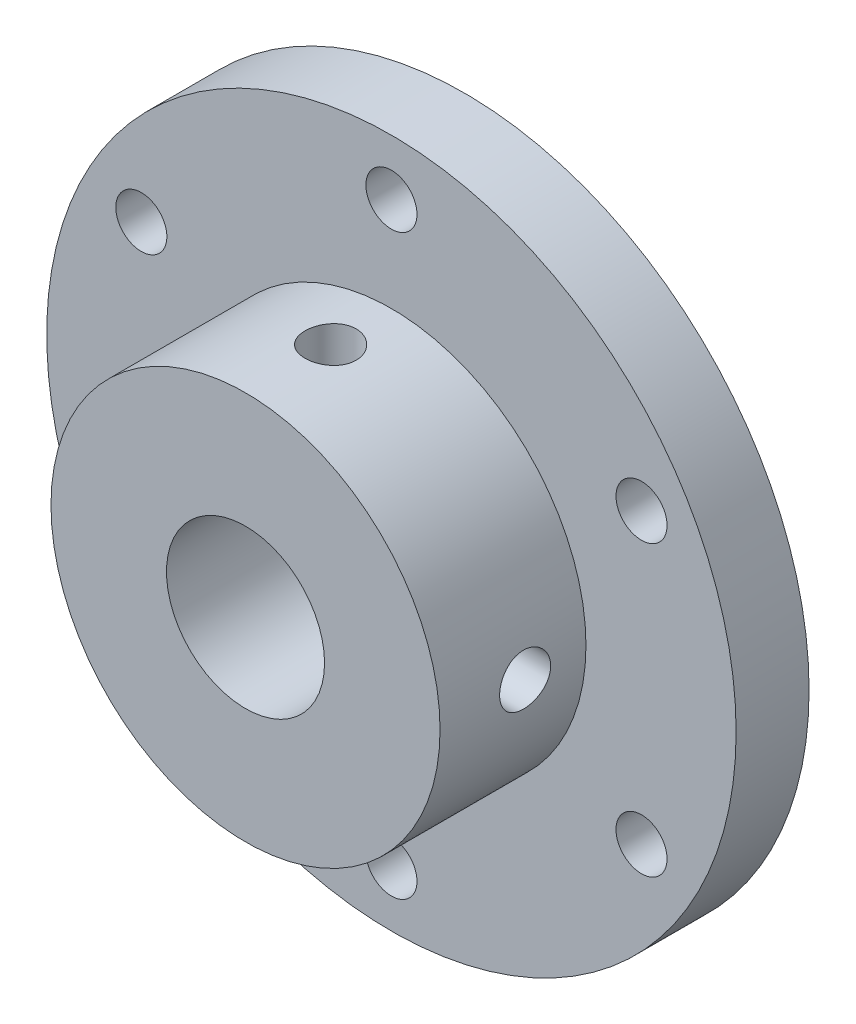
from build123d import *

# Parameters (mm, degrees)
SKETCH_1_R               = 28.35
EXTRUDE_1_DEPTH          = 6
SKETCH_2_R               = 16
EXTRUDE_2_DEPTH          = 12
SKETCH_3_R               = 6.5
CUT_EXTRUDE_1_DEPTH      = 44.948208155
HOLE_WIZARD_M5_2_D       = 4.2
PATTERN_CIRCULAR_1_COUNT = 6
CUT_EXTRUDE_3_REACH      = 57.63
SKETCH_6_R               = 2.1
PATTERN_CIRCULAR_2_COUNT = 2
PATTERN_CIRCULAR_2_ANGLE = 90


with BuildPart() as part:
    # 草圖1 → 填料-伸長1 (new body)
    with BuildSketch(Plane.XY):
        Circle(SKETCH_1_R)
    extrude(amount=EXTRUDE_1_DEPTH)

    # 草圖2 → 填料-伸長2 (add)
    with BuildSketch(Plane.XY.offset(6)):
        Circle(SKETCH_2_R)
    extrude(amount=EXTRUDE_2_DEPTH)

    # 草圖3 → 除料-伸長1 (cut, through all)
    with BuildSketch(Plane.XY.offset(18)):
        Circle(SKETCH_3_R)
    extrude(amount=-CUT_EXTRUDE_1_DEPTH, mode=Mode.SUBTRACT)

    # M5 螺紋孔2 (through all)
    with Locations(Plane(origin=(0, 0, 0), x_dir=(-1, 0, 0), z_dir=(0, 0, -1))):
        with Locations((0, 23.75)):
            hole_wizard_m5_2 = Hole(HOLE_WIZARD_M5_2_D / 2)

    # 環狀複製排列1: M5 螺紋孔2 ×6 about axis
    pattern_circular_1_axis = Axis((0, 0, 6), (0, 0, 1))
    for i in range(1, PATTERN_CIRCULAR_1_COUNT):
        add(hole_wizard_m5_2.rotate(pattern_circular_1_axis, i * 360 / PATTERN_CIRCULAR_1_COUNT), mode=Mode.SUBTRACT)

    # 草圖6 → 除料-伸長3 (cut, up to next)
    with BuildSketch(Plane(origin=(16, 0, 0), x_dir=(0, 0, -1), z_dir=(1, 0, 0)), mode=Mode.PRIVATE) as cut_extrude_3_sk1:
        with Locations((-11, 0)):
            Circle(SKETCH_6_R)
    cut_extrude_3_tool1 = extrude(cut_extrude_3_sk1.sketch, amount=-CUT_EXTRUDE_3_REACH, mode=Mode.PRIVATE) & part.part
    cut_extrude_3 = cut_extrude_3_tool1.solids().sort_by_distance((16, 0, 11))[0]
    add(cut_extrude_3, mode=Mode.SUBTRACT)

    # 環狀複製排列2: 除料-伸長3 ×2 about axis
    pattern_circular_2_axis = Axis((0, 0, 18), (0, 0, 1))
    for i in range(1, PATTERN_CIRCULAR_2_COUNT):
        add(cut_extrude_3.rotate(pattern_circular_2_axis, i * PATTERN_CIRCULAR_2_ANGLE / (PATTERN_CIRCULAR_2_COUNT - 1)), mode=Mode.SUBTRACT)


solid = part.part
